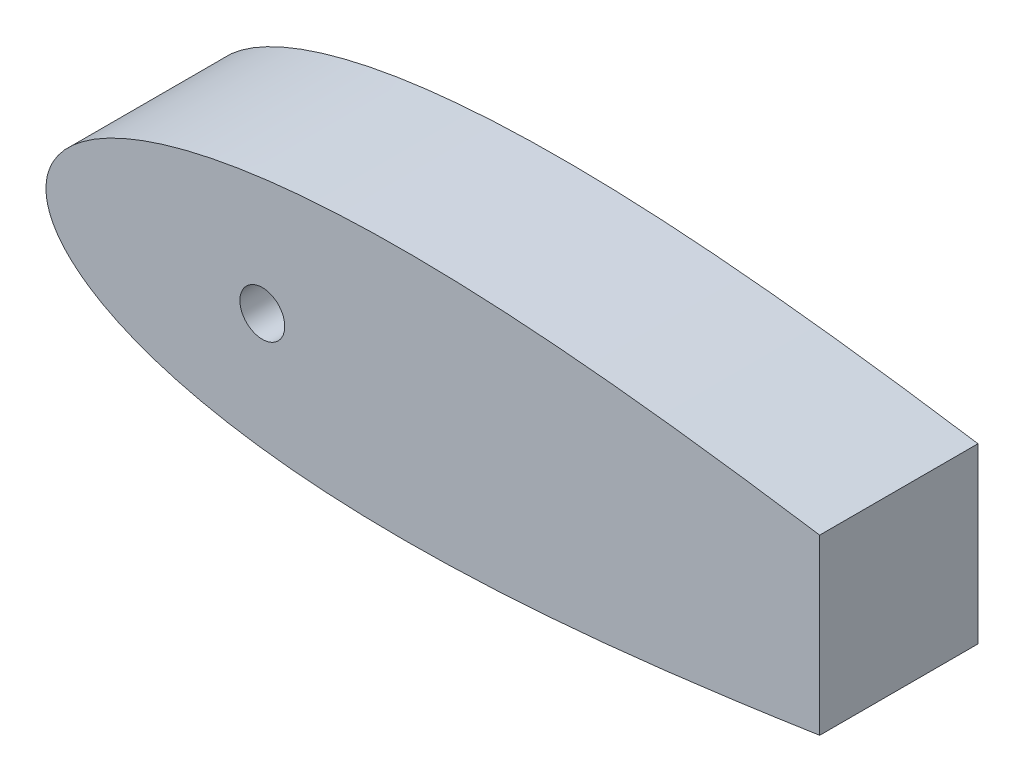
from build123d import *

# Parameters (mm, degrees)
BOSS_EXTRUDE1_DEPTH     = 76.2
SKETCH3_R               = 10.795
CUT_EXTRUDE2_DEPTH      = 76.2
SKETCH6_R               = 6.35
CUT_EXTRUDE3_DEPTH      = 53.34
CUT_EXTRUDE3_DEPTH_BACK = 0.000254
SKETCH7_R               = 1.5875
CUT_EXTRUDE4_DEPTH      = 30.48
SKETCH8_W               = 304.8
SKETCH8_H               = 127
CUT_EXTRUDE5_DEPTH      = 76.2


with BuildPart() as part:
    # Sketch1 → Boss-Extrude1 (new body)
    with BuildSketch(Plane.XY):
        with BuildLine():
            Line((643.966787522, 0), (643.599082689, 0))
            Line((643.599082689, 0), (643.599082689, -1.016))
            ThreePointArc((643.599082689, -1.016), (643.872033494, -0.540245973), (643.966787522, 0))
        make_face()
        with BuildLine():
            Line((643.599082689, -1.016), (643.599082689, 0))
            Line((643.599082689, 0), (641.567082689, 0))
            ThreePointArc((641.567082689, 0), (642.269121423, -1.135922533), (643.599082689, -1.016))
        make_face()
        with BuildLine():
            Line((641.567082689, 0), (643.599082689, 0))
            Line((643.599082689, 0), (643.966787522, 0))
            ThreePointArc((643.966787522, 0), (643.547407924, 1.075012082), (642.510849283, 1.582039112))
            add(Edge.make_bspline(
                [(642.510849283, 1.582039112), (641.993392355, 1.625070631), (638.093728429, 1.953546407), (630.413817462, 2.663385493), (619.014124193, 3.849253664), (606.374988512, 5.304428983), (592.543922516, 7.037634907), (577.585454095, 9.050636147), (561.564270734, 11.338919625), (544.549749946, 13.890665375), (526.614143658, 16.687720753), (507.832591566, 19.705111663), (488.282710288, 22.911672601), (468.044367735, 26.27043606), (447.199424328, 29.739007432), (425.831595832, 33.270324121), (404.02631566, 36.813220545), (381.870662856, 40.313266856), (359.453314895, 43.713502532), (336.86454415, 46.955447457), (314.196207315, 49.979843895), (291.541767704, 52.727712704), (268.996310773, 55.141201012), (246.65655865, 57.164603829), (224.620860897, 58.745176641), (202.989192599, 59.8341217), (181.863132616, 60.387506142), (161.345829027, 60.366961324), (141.542033828, 59.739895824), (122.558104573, 58.481758104), (104.502313427, 56.574303932), (87.485018636, 54.008935199), (71.619696083, 50.784752003), (57.023709725, 46.912543066), (43.82045433, 42.41500246), (32.141645239, 37.332204029), (22.129107375, 31.731455339), (13.932423524, 25.726412106), (7.689616489, 19.513207632), (3.463136343, 13.420354421), (1.106333228, 7.923389435), (0.154611582, 3.513796615), (0, 1.007496172), (0, 0)],
                knots=[0.020157042, 0.020157042, 0.020157042, 0.020157042, 0.021270888, 0.028552555, 0.036780684, 0.045920102, 0.055931764, 0.066772884, 0.07839713, 0.090754827, 0.103793165, 0.117456432, 0.131686226, 0.146421738, 0.161599998, 0.177156133, 0.193023668, 0.209134786, 0.225420633, 0.241811602, 0.258237647, 0.274628557, 0.290914287, 0.307025229, 0.322892517, 0.338448342, 0.353626207, 0.368361232, 0.382590428, 0.396252961, 0.409290412, 0.42164701, 0.433269881, 0.444109249, 0.45411864, 0.463255055, 0.471479114, 0.478755289, 0.485052318, 0.490344026, 0.494609833, 0.497833231, 0.5, 0.5, 0.5, 0.5], degree=3))
            Line((0, 0), (27.94, 0))
            ThreePointArc((27.94, 0), (40.64, 12.7), (53.34, 0))
            Line((53.34, 0), (93.345, 0))
            ThreePointArc((93.345, 0), (104.14, 10.795), (114.935, 0))
            Line((114.935, 0), (460.660965279, 0))
            Line((460.660965279, 0), (473.360965279, 0))
            Line((473.360965279, 0), (641.567082689, 0))
        make_face()
        with BuildLine():
            ThreePointArc((642.510849283, -1.582039112), (643.111845681, -1.408373102), (643.599082689, -1.016))
            ThreePointArc((643.599082689, -1.016), (642.269121423, -1.135922533), (641.567082689, 0))
            Line((641.567082689, 0), (473.360965279, 0))
            Line((473.360965279, 0), (460.660965279, 0))
            Line((460.660965279, 0), (114.935, 0))
            ThreePointArc((114.935, 0), (104.14, -10.795), (93.345, 0))
            Line((93.345, 0), (53.34, 0))
            ThreePointArc((53.34, 0), (40.64, -12.7), (27.94, 0))
            Line((27.94, 0), (0, 0))
            add(Edge.make_bspline(
                [(0, 0), (0, -1.007496172), (0.154611582, -3.513796615), (1.106333228, -7.923389435), (3.463136343, -13.420354421), (7.689616489, -19.513207632), (13.932423524, -25.726412106), (22.129107375, -31.731455339), (32.141645239, -37.332204029), (43.82045433, -42.41500246), (57.023709725, -46.912543066), (71.619696083, -50.784752003), (87.485018636, -54.008935199), (104.502313427, -56.574303932), (122.558104573, -58.481758104), (141.542033828, -59.739895824), (161.345829027, -60.366961324), (181.863132616, -60.387506142), (202.989192599, -59.8341217), (224.620860897, -58.745176641), (246.65655865, -57.164603829), (268.996310773, -55.141201012), (291.541767704, -52.727712704), (314.196207315, -49.979843895), (336.86454415, -46.955447457), (359.453314895, -43.713502532), (381.870662856, -40.313266856), (404.02631566, -36.813220545), (425.831595832, -33.270324121), (447.199424328, -29.739007432), (468.044367735, -26.27043606), (488.282710288, -22.911672601), (507.832591566, -19.705111663), (526.614143658, -16.687720753), (544.549749946, -13.890665375), (561.564270734, -11.338919625), (577.585454095, -9.050636147), (592.543922516, -7.037634907), (606.374988512, -5.304428983), (619.014124193, -3.849253664), (630.413817462, -2.663385493), (638.093728429, -1.953546407), (641.993392355, -1.625070631), (642.510849283, -1.582039112)],
                knots=[0.5, 0.5, 0.5, 0.5, 0.502166769, 0.505390167, 0.509655974, 0.514947682, 0.521244711, 0.528520886, 0.536744945, 0.54588136, 0.555890751, 0.566730119, 0.57835299, 0.590709588, 0.603747039, 0.617409572, 0.631638768, 0.646373793, 0.661551658, 0.677107483, 0.692974771, 0.709085713, 0.725371443, 0.741762353, 0.758188398, 0.774579367, 0.790865214, 0.806976332, 0.822843867, 0.838400002, 0.853578262, 0.868313774, 0.882543568, 0.896206835, 0.909245173, 0.92160287, 0.933227116, 0.944068236, 0.954079898, 0.963219316, 0.971447445, 0.978729112, 0.979842958, 0.979842958, 0.979842958, 0.979842958], degree=3))
        make_face()
        with BuildLine():
            ThreePointArc((643.966787522, 0), (643.872033494, -0.540245973), (643.599082689, -1.016))
            ThreePointArc((643.599082689, -1.016), (643.111845681, -1.408373102), (642.510849283, -1.582039112))
            add(Edge.make_bspline(
                [(642.510849283, -1.582039112), (644.922074617, -1.381522545), (649.798936594, -1.000308437), (656.504964311, -0.543558383), (662.850933168, -0.234427605), (666.344759683, -0.054696708), (670.56, -0.015678595), (670.56, 0)],
                knots=[0.979842958, 0.979842958, 0.979842958, 0.979842958, 0.985033212, 0.990332793, 0.994605218, 0.997832222, 1, 1, 1, 1], degree=3))
            add(Edge.make_bspline(
                [(670.56, 0), (670.56, 0.015678595), (666.344759683, 0.054696708), (662.850933168, 0.234427605), (656.504964311, 0.543558383), (649.798936594, 1.000308437), (644.922074617, 1.381522545), (642.510849283, 1.582039112)],
                knots=[0, 0, 0, 0, 0.002167778, 0.005394782, 0.009667207, 0.014966788, 0.020157042, 0.020157042, 0.020157042, 0.020157042], degree=3))
            ThreePointArc((642.510849283, 1.582039112), (643.547407924, 1.075012082), (643.966787522, 0))
        make_face()
        with BuildLine():
            ThreePointArc((53.34, 0), (40.64, 12.7), (27.94, 0))
            Line((27.94, 0), (53.34, 0))
        make_face()
        with BuildLine():
            Line((53.34, 0), (27.94, 0))
            ThreePointArc((27.94, 0), (40.64, -12.7), (53.34, 0))
        make_face()
        with BuildLine():
            ThreePointArc((93.345, 0), (104.14, -10.795), (114.935, 0))
            Line((114.935, 0), (93.345, 0))
        make_face()
        with BuildLine():
            Line((93.345, 0), (114.935, 0))
            ThreePointArc((114.935, 0), (104.14, 10.795), (93.345, 0))
        make_face()
    extrude(amount=BOSS_EXTRUDE1_DEPTH)

    # Sketch3 → Cut-Extrude2 (cut)
    with BuildSketch(Plane.XY.offset(76.2)):
        with Locations((104.139232412, 0)):
            Circle(SKETCH3_R)
    extrude(amount=-CUT_EXTRUDE2_DEPTH, mode=Mode.SUBTRACT)

    # Sketch6 → Cut-Extrude3 (cut, two sides)
    with BuildSketch(Plane(origin=(0, 0, 0), x_dir=(0, 0, -1), z_dir=(1, 0, 0))) as cut_extrude3_sk:
        with Locations((-20.32, 0)):
            Circle(SKETCH6_R)
    extrude(amount=CUT_EXTRUDE3_DEPTH, mode=Mode.SUBTRACT)
    extrude(cut_extrude3_sk.sketch, amount=-CUT_EXTRUDE3_DEPTH_BACK, mode=Mode.SUBTRACT)

    # Sketch7 → Cut-Extrude4 (cut)
    with BuildSketch(Plane(origin=(0, 0, 0), x_dir=(-1, 0, 0), z_dir=(0, 0, -1))):
        with Locations((-38.1, 0)):
            Circle(SKETCH7_R)
        with Locations((-50.8, 0)):
            Circle(SKETCH7_R)
    extrude(amount=-CUT_EXTRUDE4_DEPTH, mode=Mode.SUBTRACT)

    # Sketch8 → Cut-Extrude5 (cut)
    with BuildSketch(Plane(origin=(0, 0, 0), x_dir=(-1, 0, 0), z_dir=(0, 0, -1))):
        with Locations((-524.843319628, 0.490119432)):
            Rectangle(SKETCH8_W, SKETCH8_H)
    extrude(amount=-CUT_EXTRUDE5_DEPTH, mode=Mode.SUBTRACT)


solid = part.part
